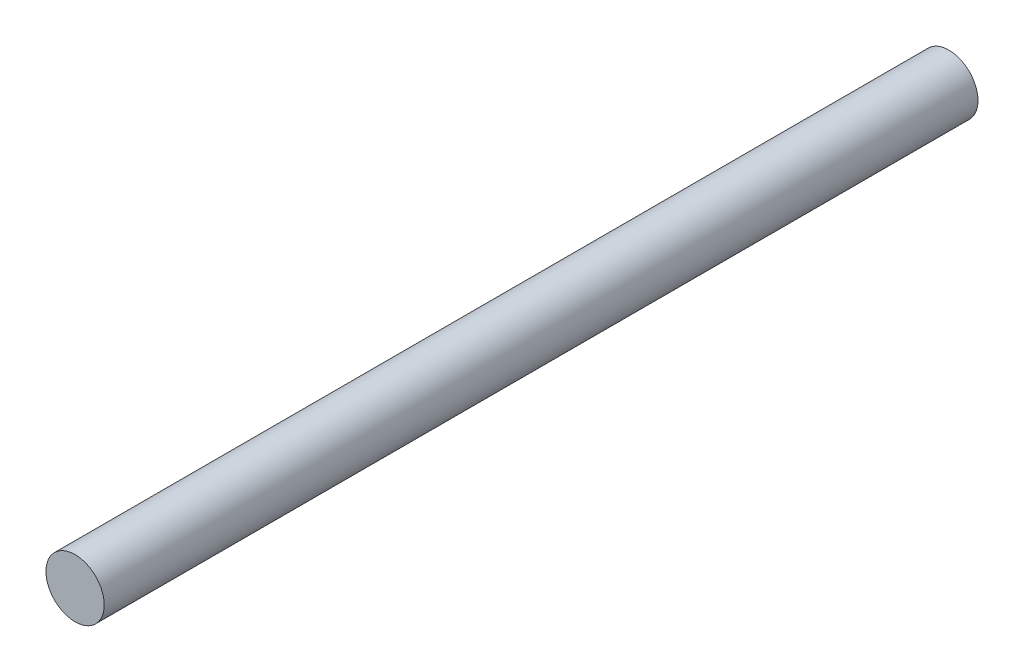
from build123d import *

# Parameters (mm, degrees)
SKETCH_1_R      = 5
EXTRUDE_1_DEPTH = 150


with BuildPart() as part:
    # 草图1 → 凸台-拉伸1 (new body)
    with BuildSketch(Plane.XY):
        Circle(SKETCH_1_R)
    extrude(amount=EXTRUDE_1_DEPTH)


solid = part.part
